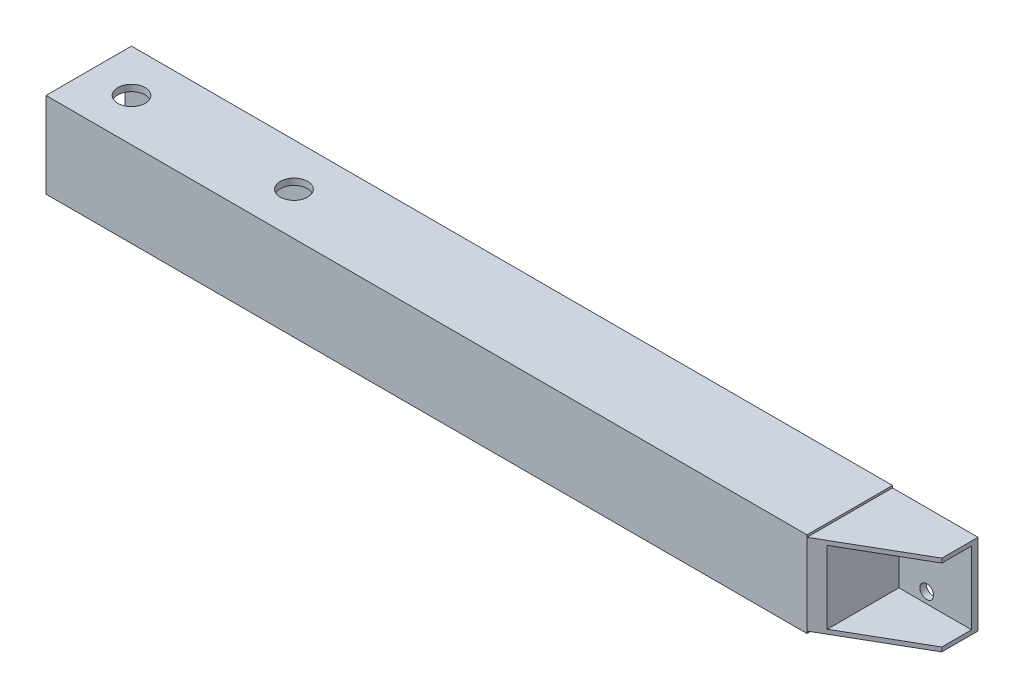
from build123d import *

# Parameters (mm, degrees)
ESQUISSE1_W             = 178
ESQUISSE1_H             = 20
ESQUISSE1_W_2           = 20
BOSS_EXTRU_1_DEPTH      = 20
ESQUISSE3_W             = 17
ESQUISSE3_H             = 17
ENL_V_MAT_EXTRU_1_DEPTH = 178
ESQUISSE4_W             = 17
ESQUISSE4_H             = 17
ENL_V_MAT_EXTRU_2_DEPTH = 18.5
CHANFREIN1_SIZE         = 20
CHANFREIN1_SIZE2        = 11.547005384
ESQUISSE5_W             = 20
ESQUISSE5_H             = 0.5
ENL_V_MAT_EXTRU_3_DEPTH = 24
ESQUISSE6_R             = 1.6
ENL_V_MAT_EXTRU_4_DEPTH = 24
ESQUISSE7_R             = 3.2
ENL_V_MAT_EXTRU_5_DEPTH = 34


with BuildPart() as part:
    # Esquisse1 → Boss.-Extru.1 (new body)
    with BuildSketch(Plane.XY):
        Rectangle(ESQUISSE1_W, ESQUISSE1_H)
        with Locations((99, 0)):
            Rectangle(ESQUISSE1_W_2, ESQUISSE1_H)
    extrude(amount=BOSS_EXTRU_1_DEPTH)

    # Esquisse3 → Enlèv. mat.-Extru.1 (cut)
    with BuildSketch(Plane.ZY.offset(89)):
        with Locations((10, 0)):
            Rectangle(ESQUISSE3_W, ESQUISSE3_H)
    extrude(amount=-ENL_V_MAT_EXTRU_1_DEPTH, mode=Mode.SUBTRACT)

    # Esquisse4 → Enlèv. mat.-Extru.2 (cut)
    with BuildSketch(Plane.XY.offset(20)):
        with Locations((100.5, 0)):
            Rectangle(ESQUISSE4_W, ESQUISSE4_H)
    extrude(amount=-ENL_V_MAT_EXTRU_2_DEPTH, mode=Mode.SUBTRACT)

    # Chanfrein1
    chanfrein1_edges = [part.edges().sort_by_distance(p)[0] for p in [
        (109, 9.25, 20),
    ]]
    chanfrein1_side = [part.faces().sort_by_distance(p)[0] for p in [
        (2.875374557, 0, 20),
    ]]
    chamfer(chanfrein1_edges, length=CHANFREIN1_SIZE, length2=CHANFREIN1_SIZE2, reference=chanfrein1_side[0])

    # Esquisse5 → Enlèv. mat.-Extru.3 (cut)
    with BuildSketch(Plane(origin=(0, 0, 0), x_dir=(-1, 0, 0), z_dir=(0, 0, -1))):
        with Locations((-99, 9.75)):
            Rectangle(ESQUISSE5_W, ESQUISSE5_H)
        with Locations((-99, -9.75)):
            Rectangle(ESQUISSE5_W, ESQUISSE5_H)
    extrude(amount=-ENL_V_MAT_EXTRU_3_DEPTH, mode=Mode.SUBTRACT)

    # Esquisse6 → Enlèv. mat.-Extru.4 (cut)
    with BuildSketch(Plane(origin=(0, 0, 0), x_dir=(-1, 0, 0), z_dir=(0, 0, -1))):
        with Locations((-98.5, 6)):
            Circle(ESQUISSE6_R)
        with Locations((-98.5, -6)):
            Circle(ESQUISSE6_R)
    extrude(amount=-ENL_V_MAT_EXTRU_4_DEPTH, mode=Mode.SUBTRACT)

    # Esquisse7 → Enlèv. mat.-Extru.5 (cut)
    with BuildSketch(Plane.XZ.offset(10)):
        with Locations((-79, 10)):
            Circle(ESQUISSE7_R)
        with Locations((-41, 10)):
            Circle(ESQUISSE7_R)
    extrude(amount=-ENL_V_MAT_EXTRU_5_DEPTH, mode=Mode.SUBTRACT)


solid = part.part
